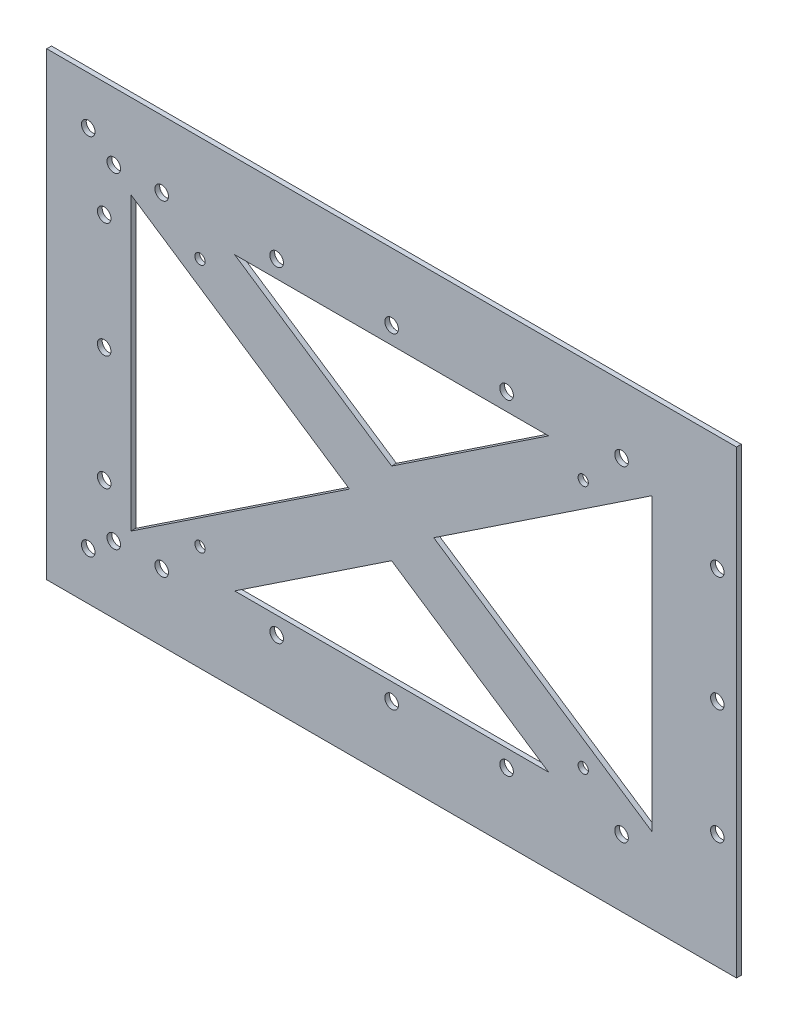
from build123d import *

# Parameters (mm, degrees)
SKETCH1_W           = 228.6
SKETCH1_H           = 152.4
BOSS_EXTRUDE1_DEPTH = 1.5875
SKETCH2_R           = 2.25
CUT_EXTRUDE1_DEPTH  = 2.5875
SKETCH3_R           = 1.7
CUT_EXTRUDE2_DEPTH  = 2.5875


with BuildPart() as part:
    # Sketch1 → Boss-Extrude1 (new body)
    with BuildSketch(Plane.XY):
        Rectangle(SKETCH1_W, SKETCH1_H)
        Polygon((-52.017124101, 48.26), (52.017124101, 48.26), (0, 13.581917266), align=None, mode=Mode.SUBTRACT)
        Polygon((-86.36, 48.26), (-86.36, -48.26), (-13.97, 0), align=None, mode=Mode.SUBTRACT)
        Polygon((0, -13.581917266), (-52.017124101, -48.26), (52.017124101, -48.26), align=None, mode=Mode.SUBTRACT)
        Polygon((13.97, 0), (86.36, 48.26), (86.36, -48.26), align=None, mode=Mode.SUBTRACT)
    extrude(amount=BOSS_EXTRUDE1_DEPTH)

    # Sketch2 → Cut-Extrude1 (cut, through all)
    with BuildSketch(Plane.XY.offset(1.5875)):
        with Locations((-100.541666667, 60.325)):
            Circle(SKETCH2_R)
        with Locations((-92.075, 53.975)):
            Circle(SKETCH2_R)
        with Locations((-95.255, 38.1)):
            Circle(SKETCH2_R)
        with Locations((-95.255, 0)):
            Circle(SKETCH2_R)
        with Locations((-95.255, -38.1)):
            Circle(SKETCH2_R)
        with Locations((-92.075, -53.975)):
            Circle(SKETCH2_R)
        with Locations((-100.541666667, -60.325)):
            Circle(SKETCH2_R)
        with Locations((107.95, 38.1)):
            Circle(SKETCH2_R)
        with Locations((107.95, 0)):
            Circle(SKETCH2_R)
        with Locations((107.95, -38.1)):
            Circle(SKETCH2_R)
        with Locations((-76.2, 53.975)):
            Circle(SKETCH2_R)
        with Locations((-76.2, -53.975)):
            Circle(SKETCH2_R)
        with Locations((-38.1, -53.975)):
            Circle(SKETCH2_R)
        with Locations((-38.1, 53.975)):
            Circle(SKETCH2_R)
        with Locations((0, -53.975)):
            Circle(SKETCH2_R)
        with Locations((0, 53.975)):
            Circle(SKETCH2_R)
        with Locations((38.1, -53.975)):
            Circle(SKETCH2_R)
        with Locations((38.1, 53.975)):
            Circle(SKETCH2_R)
        with Locations((76.2, -53.975)):
            Circle(SKETCH2_R)
        with Locations((76.2, 53.975)):
            Circle(SKETCH2_R)
    extrude(amount=-CUT_EXTRUDE1_DEPTH, mode=Mode.SUBTRACT)

    # Sketch3 → Cut-Extrude2 (cut, through all)
    with BuildSketch(Plane.XY.offset(1.5875)):
        with Locations((-63.5, 41.275)):
            Circle(SKETCH3_R)
        with Locations((63.5, 41.275)):
            Circle(SKETCH3_R)
        with Locations((-63.5, -41.275)):
            Circle(SKETCH3_R)
        with Locations((63.5, -41.275)):
            Circle(SKETCH3_R)
    extrude(amount=-CUT_EXTRUDE2_DEPTH, mode=Mode.SUBTRACT)


solid = part.part
